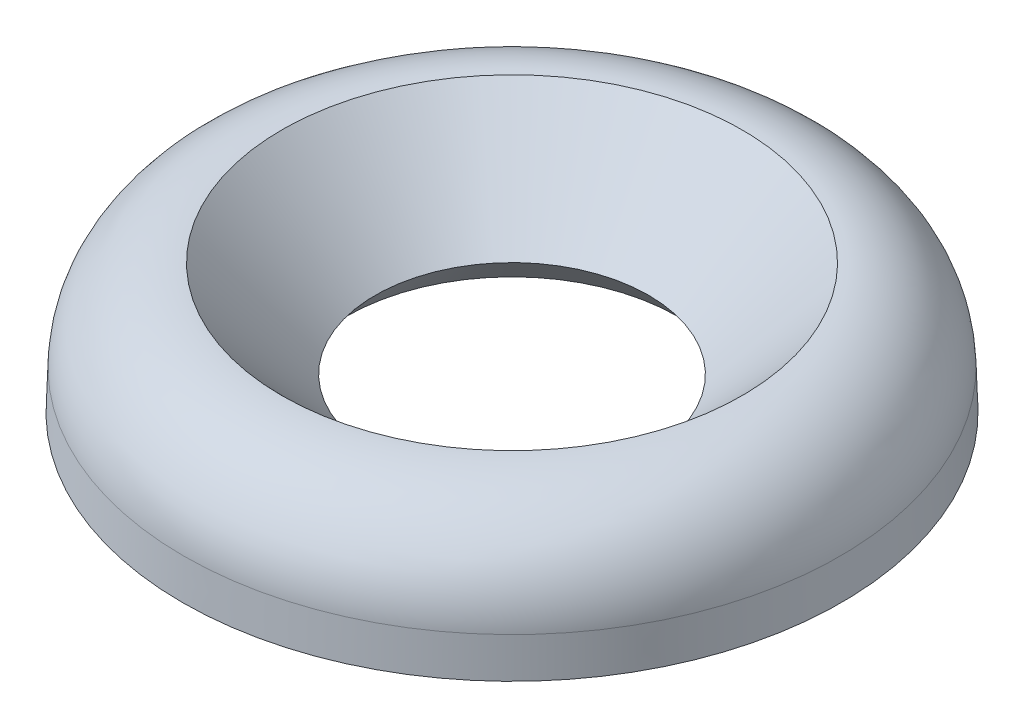
from build123d import *


with BuildPart() as part:
    # Sketch2 → Revolve1 (revolve)
    with BuildSketch(Plane.XY):
        with BuildLine():
            Line((-8.87095, 4.9911), (-5.2705, 1.27))
            Line((-5.2705, 1.27), (-6.392427617, 0))
            Line((-6.392427617, 0), (-12.7, 0))
            Line((-12.7, 0), (-12.646813167, 1.52307162))
            ThreePointArc((-12.646813167, 1.52307162), (-11.484828724, 4.047470654), (-8.87095, 4.9911))
        make_face()
    revolve(axis=Axis((0, 9.185150429, 0), (0, -1, 0)))


solid = part.part
